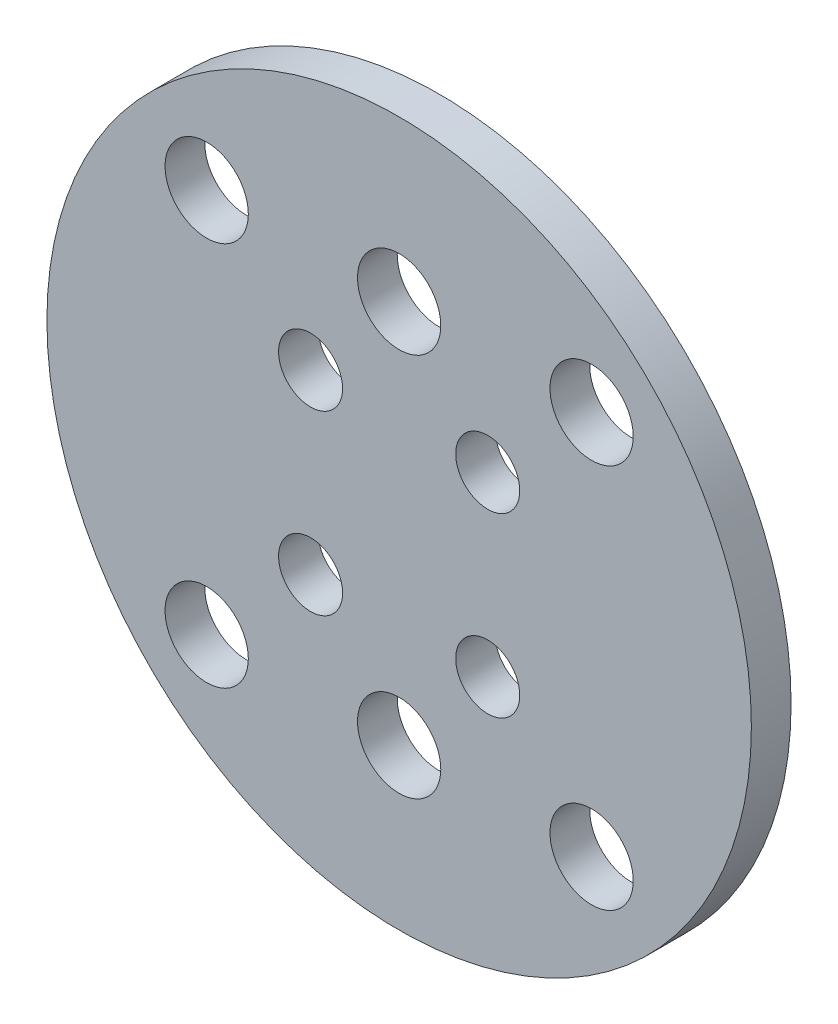
from build123d import *

# Parameters (mm, degrees)
SKETCH1_R           = 27.5
SKETCH1_R_2         = 2.5
SKETCH1_R_3         = 3.25
BOSS_EXTRUDE1_DEPTH = 3.1


with BuildPart() as part:
    # Sketch1 → Boss-Extrude1 (new body)
    with BuildSketch(Plane.XY):
        Circle(SKETCH1_R)
        with Locations((-6.914797213, 6.914797213)):
            Circle(SKETCH1_R_2, mode=Mode.SUBTRACT)
        with Locations((6.914797213, 6.914797213)):
            Circle(SKETCH1_R_2, mode=Mode.SUBTRACT)
        with Locations((6.914797213, -6.914797213)):
            Circle(SKETCH1_R_2, mode=Mode.SUBTRACT)
        with Locations((-6.914797213, -6.914797213)):
            Circle(SKETCH1_R_2, mode=Mode.SUBTRACT)
        with Locations((15.0260191, -15.0260191)):
            Circle(SKETCH1_R_3, mode=Mode.SUBTRACT)
        with Locations((-15.0260191, -15.0260191)):
            Circle(SKETCH1_R_3, mode=Mode.SUBTRACT)
        with Locations((-15.0260191, 15.0260191)):
            Circle(SKETCH1_R_3, mode=Mode.SUBTRACT)
        with Locations((15.0260191, 15.0260191)):
            Circle(SKETCH1_R_3, mode=Mode.SUBTRACT)
        with Locations((0, -15)):
            Circle(SKETCH1_R_3, mode=Mode.SUBTRACT)
        with Locations((0, 15)):
            Circle(SKETCH1_R_3, mode=Mode.SUBTRACT)
    extrude(amount=BOSS_EXTRUDE1_DEPTH)


solid = part.part
